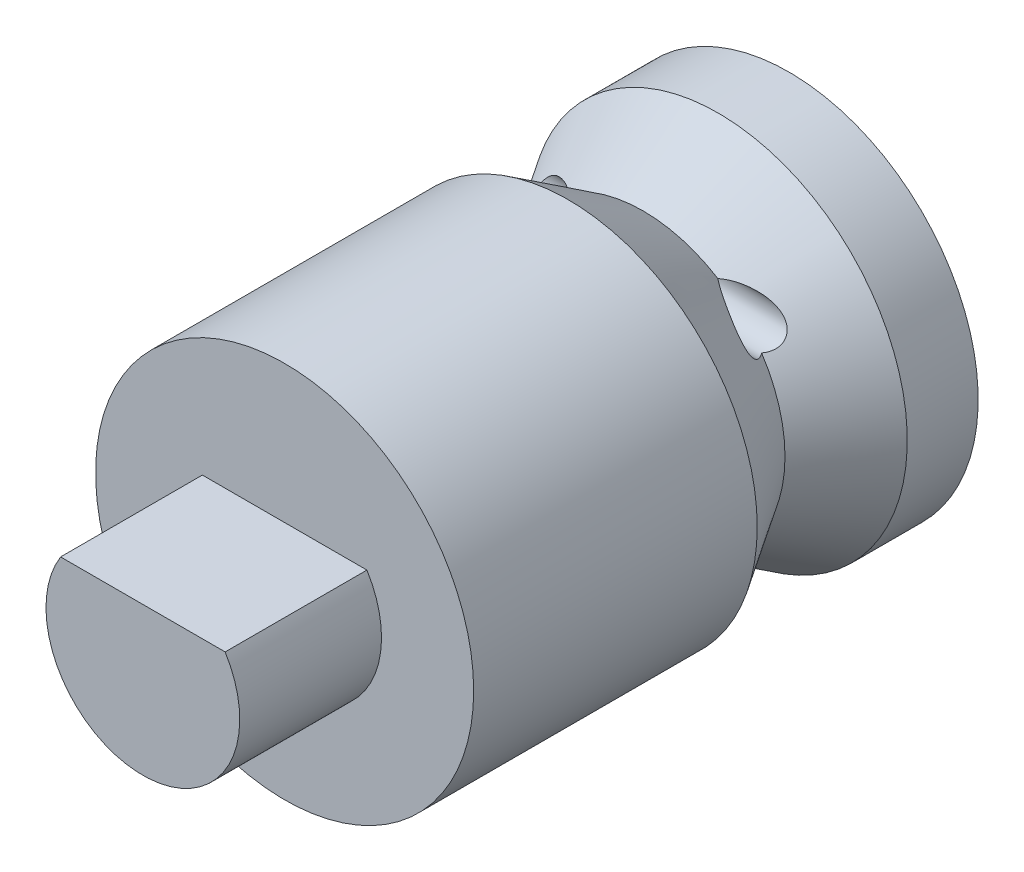
from build123d import *
from build123d.topology import SkipClean

# Parameters (mm, degrees)
SKETCH1_R           = 4
BOSS_EXTRUDE1_DEPTH = 3.175
CUT_EXTRUDE1_DEPTH  = 7.48695807
SKETCH4_R           = 4
BOSS_EXTRUDE2_DEPTH = 6
SKETCH5_R           = 0.45
CUT_EXTRUDE2_DEPTH  = 4
SKETCH6_R           = 4
BOSS_EXTRUDE3_DEPTH = 1.5
BOSS_EXTRUDE4_DEPTH = 3
CUT_EXTRUDE3_START  = -5
CUT_EXTRUDE3_DEPTH  = 5


with BuildPart() as part:
    # Sketch1 → Boss-Extrude1 (new body)
    with BuildSketch(Plane.XY):
        Circle(SKETCH1_R)
    extrude(amount=BOSS_EXTRUDE1_DEPTH)

    # Sketch2 → Cut-Extrude1 (cut, through all)
    with BuildSketch(Plane.XY.offset(3.175)):
        with BuildLine():
            Line((-1.375, 1.082531755), (1.375, 1.082531755))
            ThreePointArc((1.375, 1.082531755), (0, -1.75), (-1.375, 1.082531755))
        make_face()
    extrude(amount=-CUT_EXTRUDE1_DEPTH, mode=Mode.SUBTRACT)

    # Sketch3 → Cut-Revolve1 (revolve, cut)
    with BuildSketch(Plane(origin=(0, 0, 0), x_dir=(0, 0, -1), z_dir=(1, 0, 0)), mode=Mode.PRIVATE) as cut_revolve1_sk:
        Polygon((-3.175, 4), (0, 4), (-1.5875, 3), align=None)
    revolve(cut_revolve1_sk.sketch.rotate(Axis((0, 0, 3.175), (0, 0, -1)), 90), axis=Axis((0, 0, 3.175), (0, 0, -1)), mode=Mode.SUBTRACT)

    # Sketch4 → Boss-Extrude2 (add)
    with BuildSketch(Plane.XY.offset(3.175)):
        Circle(SKETCH4_R)
    extrude(amount=BOSS_EXTRUDE2_DEPTH)

    # Sketch5 → Cut-Extrude2 (cut, symmetric)
    with BuildSketch(Plane(origin=(0, 0, 0), x_dir=(0, 0, -1), z_dir=(1, 0, 0))):
        with Locations(Location((-1.5875, 2.1, 0), (0, 0, 89.999570565))):
            Circle(SKETCH5_R)
    extrude(amount=CUT_EXTRUDE2_DEPTH, both=True, mode=Mode.SUBTRACT)

    # Sketch6 → Boss-Extrude3 (add)
    with SkipClean():  # the faces are left unmerged after this step: merging them gives an invalid solid
        with BuildSketch(Plane(origin=(0, 0, 0), x_dir=(-1, 0, 0), z_dir=(0, 0, -1))):
            with Locations(Location((0, 0, 0), (0, 0, 180))):
                Circle(SKETCH6_R)
            with BuildLine():
                ThreePointArc((1.375, 1.082531755), (0, -1.75), (-1.375, 1.082531755))
                Line((-1.375, 1.082531755), (1.375, 1.082531755))
            make_face(mode=Mode.SUBTRACT)
        extrude(amount=BOSS_EXTRUDE3_DEPTH)

    # Sketch7 → Boss-Extrude4 (add)
    with SkipClean():  # the faces are left unmerged after this step: merging them gives an invalid solid
        with BuildSketch(Plane.XY.offset(9.175)):
            with BuildLine():
                Line((1.740869036, 1.082531755), (-1.740869036, 1.082531755))
                ThreePointArc((-1.740869036, 1.082531755), (0, -2.05), (1.740869036, 1.082531755))
            make_face()
        extrude(amount=BOSS_EXTRUDE4_DEPTH)

    # Sketch8 → Cut-Extrude3 (cut)
    with SkipClean():  # the faces are left unmerged after this step: merging them gives an invalid solid
        with BuildSketch(Plane(origin=(0, 0, 3.175), x_dir=(-1, 0, 0), z_dir=(0, 0, -1)).offset(CUT_EXTRUDE3_START)):
            with BuildLine():
                Line((1.375, 1.082531755), (-1.375, 1.082531755))
                ThreePointArc((-1.375, 1.082531755), (0, -1.75), (1.375, 1.082531755))
            make_face()
        extrude(amount=CUT_EXTRUDE3_DEPTH, mode=Mode.SUBTRACT)


solid = part.part
